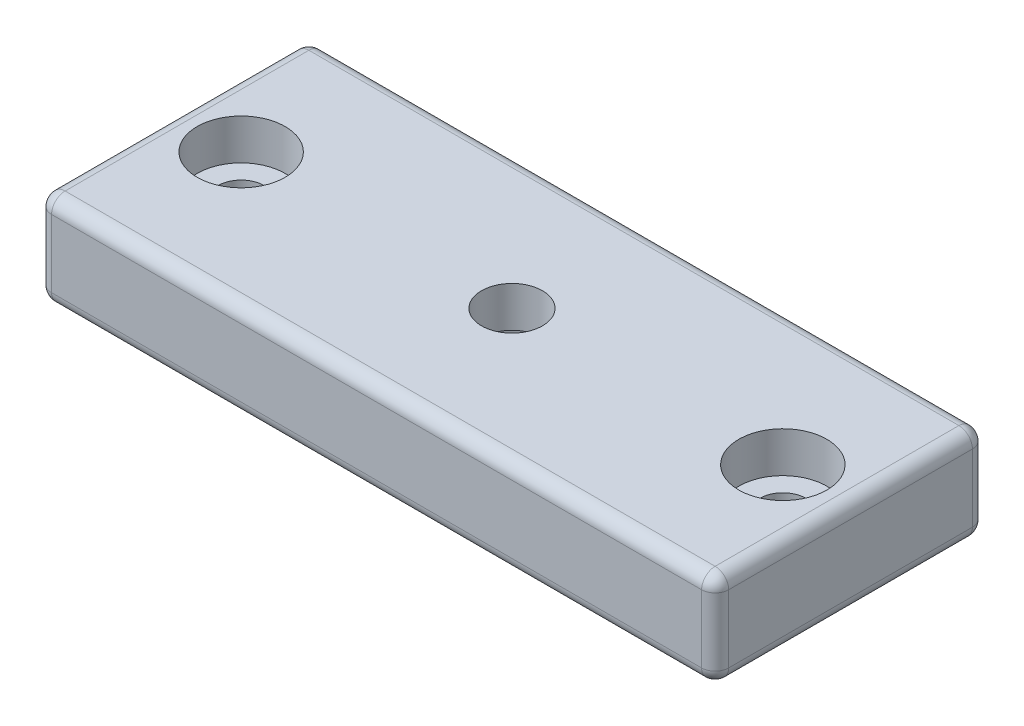
from build123d import *

# Parameters (mm, degrees)
SKETCH1_W                      = 50
SKETCH1_H                      = 20
EXTRUDE1_DEPTH                 = 7
CBORE_FOR_M3_SHCS1_D           = 3.4
CBORE_FOR_M3_SHCS1_CBORE_D     = 6.5
CBORE_FOR_M3_SHCS1_CBORE_DEPTH = 3
FILLET1_R                      = 1
CBORE_FOR_M4_SHCS1_D           = 4.5
CBORE_FOR_M4_SHCS1_CBORE_D     = 8
CBORE_FOR_M4_SHCS1_CBORE_DEPTH = 4


with BuildPart() as part:
    # Sketch1 → Extrude1 (new body)
    with BuildSketch(Plane(origin=(0, 0, 0), x_dir=(1, 0, 0), z_dir=(0, 1, 0))):
        Rectangle(SKETCH1_W, SKETCH1_H)
    extrude(amount=EXTRUDE1_DEPTH)

    # CBORE for M3 SHCS1 (through all)
    with Locations(Plane(origin=(0, 7, 0), x_dir=(-1, 0, 0), z_dir=(0, 1, 0))):
        with Locations((20, 0), (-20, 0)):
            CounterBoreHole(CBORE_FOR_M3_SHCS1_D / 2, CBORE_FOR_M3_SHCS1_CBORE_D / 2, CBORE_FOR_M3_SHCS1_CBORE_DEPTH)

    # Fillet1
    fillet1_edges = [part.edges().sort_by_distance(p)[0] for p in [
        (25, 7, 0),
        (0, 7, -10),
        (-25, 7, 0),
        (0, 0, -10),
        (25, 0, 0),
        (0, 0, 10),
        (-25, 0, 0),
        (0, 7, 10),
        (-25, 3.5, -10),
        (25, 3.5, -10),
        (25, 3.5, 10),
        (-25, 3.5, 10),
    ]]
    fillet(fillet1_edges, radius=FILLET1_R)

    # CBORE for M4 SHCS1 (through all)
    with Locations(Plane(origin=(0, 0, 0), x_dir=(0, 0, -1), z_dir=(0, -1, 0))):
        with Locations((0, 0)):
            CounterBoreHole(CBORE_FOR_M4_SHCS1_D / 2, CBORE_FOR_M4_SHCS1_CBORE_D / 2, CBORE_FOR_M4_SHCS1_CBORE_DEPTH)


solid = part.part
